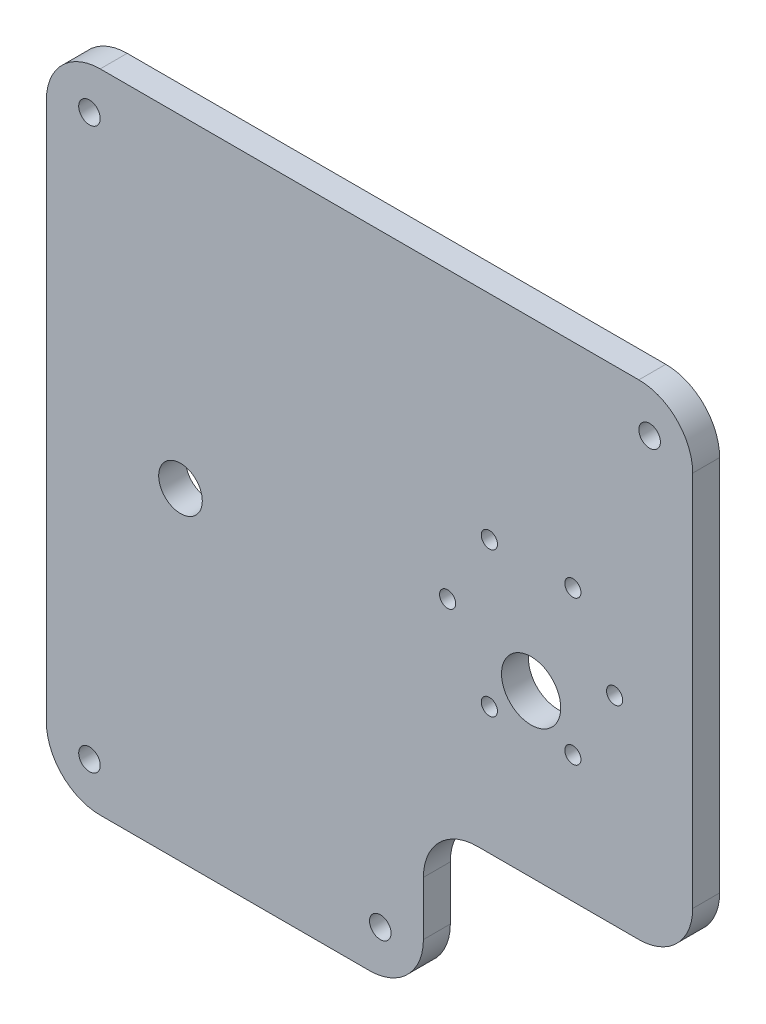
from build123d import *

# Parameters (mm, degrees)
SALIENTE_EXTRUIR1_DEPTH = 5
CROQUIS2_R              = 2
CROQUIS2_R_2            = 4.05
CROQUIS2_R_3            = 1.5
CROQUIS2_R_4            = 5.5
CORTAR_EXTRUIR1_DEPTH   = 10


with BuildPart() as part:
    # Croquis1 → Saliente-Extruir1 (new body)
    with BuildSketch(Plane.XY):
        with BuildLine():
            Line((110, 30), (80, 30))
            ThreePointArc((80, 30), (72.928932188, 27.071067812), (70, 20))
            Line((70, 20), (70, 10))
            ThreePointArc((70, 10), (67.071067812, 2.928932188), (60, 0))
            Line((60, 0), (10, 0))
            ThreePointArc((10, 0), (2.928932188, 2.928932188), (0, 10))
            Line((0, 10), (0, 110))
            ThreePointArc((0, 110), (2.928932188, 117.071067812), (10, 120))
            Line((10, 120), (110, 120))
            ThreePointArc((110, 120), (117.071067812, 117.071067812), (120, 110))
            Line((120, 110), (120, 40))
            ThreePointArc((120, 40), (117.071067812, 32.928932188), (110, 30))
        make_face()
    extrude(amount=SALIENTE_EXTRUIR1_DEPTH)

    # Croquis2 → Cortar-Extruir1 (cut)
    with BuildSketch(Plane.XY.offset(5)):
        with Locations((8, 112)):
            Circle(CROQUIS2_R)
        with Locations((8, 8)):
            Circle(CROQUIS2_R)
        with Locations((112, 8)):
            Circle(CROQUIS2_R)
        with Locations((112, 112)):
            Circle(CROQUIS2_R)
        with Locations((62, 8)):
            Circle(CROQUIS2_R)
        with Locations((24.9, 60)):
            Circle(CROQUIS2_R_2)
        with Locations((82.25, 80.423393759)):
            Circle(CROQUIS2_R_3)
        with Locations((97.75, 80.423393759)):
            Circle(CROQUIS2_R_3)
        with Locations((105.5, 67)):
            Circle(CROQUIS2_R_3)
        with Locations((97.75, 53.576606241)):
            Circle(CROQUIS2_R_3)
        with Locations((82.25, 53.576606241)):
            Circle(CROQUIS2_R_3)
        with Locations((74.5, 67)):
            Circle(CROQUIS2_R_3)
        with Locations((90, 60)):
            Circle(CROQUIS2_R_4)
    extrude(amount=-CORTAR_EXTRUIR1_DEPTH, mode=Mode.SUBTRACT)


solid = part.part
